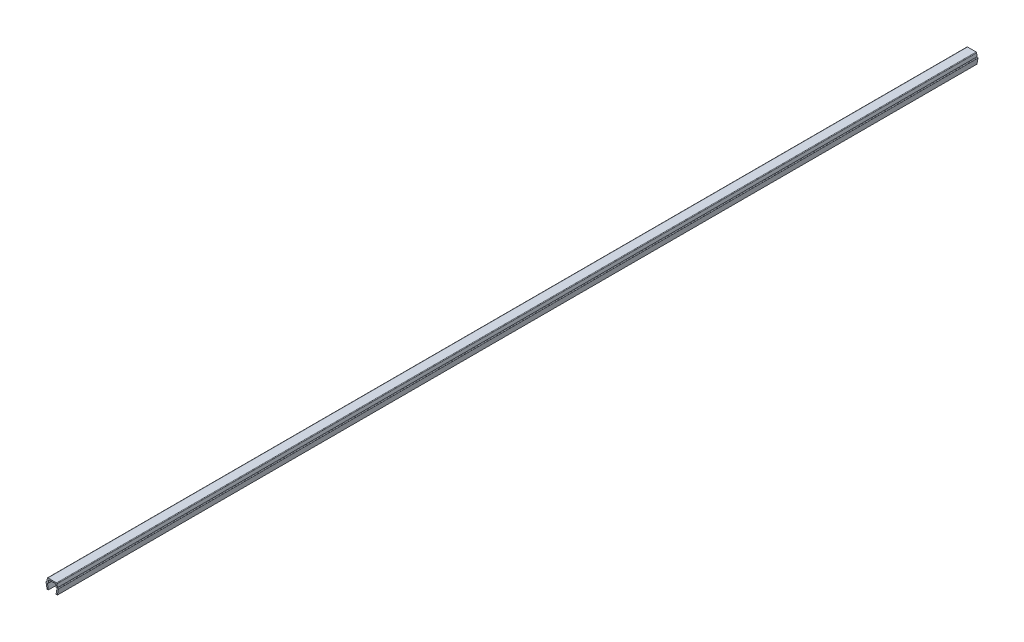
from build123d import *

# Parameters (mm, degrees)
BOSS_EXTRUDE1_DEPTH = 266.75


with BuildPart() as part:
    # Sketch1 → Boss-Extrude1 (new body, symmetric)
    with BuildSketch(Plane.XY):
        with BuildLine():
            Line((-3.6, 3.35), (-3, 0))
            Line((-3, 0), (-2.2, 0))
            Line((-2.2, 0), (-2.735217071, 2.988295315))
            ThreePointArc((-2.735217071, 2.988295315), (-2.659117427, 3.274614514), (-2.390699246, 3.4))
            Line((-2.390699246, 3.4), (-2.2, 3.4))
            Line((-2.2, 3.4), (-2.070472639, 4.88050451))
            ThreePointArc((-2.070472639, 4.88050451), (-1.958261067, 5.108047068), (-1.721804495, 5.2))
            Line((-1.721804495, 5.2), (1.721804495, 5.2))
            ThreePointArc((1.721804495, 5.2), (1.958261067, 5.108047068), (2.070472639, 4.88050451))
            Line((2.070472639, 4.88050451), (2.2, 3.4))
            Line((2.2, 3.4), (2.390699246, 3.4))
            ThreePointArc((2.390699246, 3.4), (2.659117427, 3.274614514), (2.735217071, 2.988295315))
            Line((2.735217071, 2.988295315), (2.2, 0))
            Line((2.2, 0), (3, 0))
            Line((3, 0), (3.6, 3.35))
            ThreePointArc((3.6, 3.35), (3.497487373, 3.597487373), (3.25, 3.7))
            Line((3.25, 3.7), (3, 3.7))
            Line((3, 3.7), (2.835477174, 5.58050451))
            ThreePointArc((2.835477174, 5.58050451), (2.723265602, 5.808047068), (2.486809029, 5.9))
            Line((2.486809029, 5.9), (-2.486809029, 5.9))
            ThreePointArc((-2.486809029, 5.9), (-2.723265602, 5.808047068), (-2.835477174, 5.58050451))
            Line((-2.835477174, 5.58050451), (-3, 3.7))
            Line((-3, 3.7), (-3.25, 3.7))
            ThreePointArc((-3.25, 3.7), (-3.497487373, 3.597487373), (-3.6, 3.35))
        make_face()
    extrude(amount=BOSS_EXTRUDE1_DEPTH, both=True)


solid = part.part
